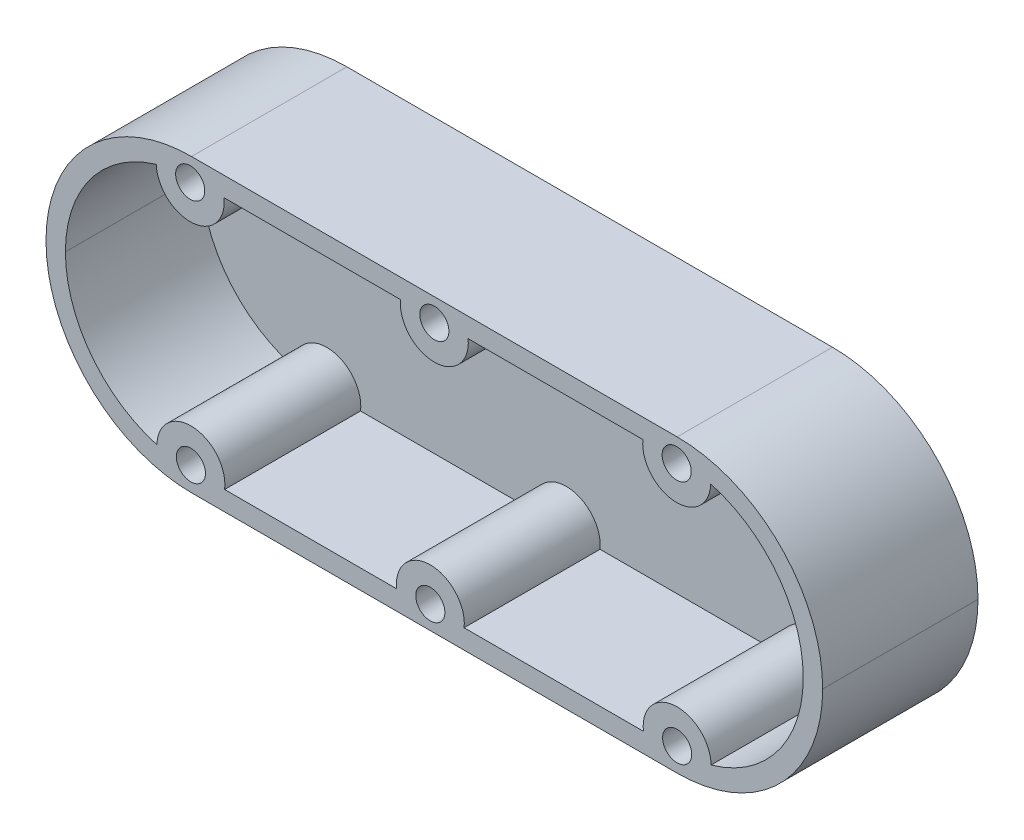
from build123d import *

# Parameters (mm, degrees)
SKETCH3_R           = 1.5
BOSS_EXTRUDE2_DEPTH = 16
SHELL4_T            = -2


with BuildPart() as part:
    # Sketch3 → Boss-Extrude2 (new body)
    with BuildSketch(Plane.XY):
        with BuildLine():
            Line((40.605667182, -0.784898421), (40.605667182, -0.764898421))
            ThreePointArc((40.605667182, -0.764898421), (36.215197832, 9.834632229), (25.615667182, 14.225101579))
            Line((25.615667182, 14.225101579), (-24.404332818, 14.225101579))
            ThreePointArc((-24.404332818, 14.225101579), (-35.003863468, 9.834632229), (-39.394332818, -0.764898421))
            Line((-39.394332818, -0.764898421), (-39.394332818, -0.784898421))
            ThreePointArc((-39.394332818, -0.784898421), (-35.003863468, -11.384429071), (-24.404332818, -15.774898421))
            Line((-24.404332818, -15.774898421), (25.615667182, -15.774898421))
            ThreePointArc((25.615667182, -15.774898421), (36.215197832, -11.384429071), (40.605667182, -0.784898421))
        make_face()
        with Locations(Location((25.569857848, 11.840225967, 0), (0, 0, 180))):
            Circle(SKETCH3_R, mode=Mode.SUBTRACT)
        with Locations(Location((25.615667182, -13.354907477, 0), (0, 0, 180))):
            Circle(SKETCH3_R, mode=Mode.SUBTRACT)
        with Locations(Location((0.19338318, -13.400716811, 0), (0, 0, 180))):
            Circle(SKETCH3_R, mode=Mode.SUBTRACT)
        with Locations(Location((0.605667182, 11.8860353, 0), (0, 0, 180))):
            Circle(SKETCH3_R, mode=Mode.SUBTRACT)
        with Locations(Location((-24.541760819, 11.840225967, 0), (0, 0, 180))):
            Circle(SKETCH3_R, mode=Mode.SUBTRACT)
        with Locations(Location((-24.468118501, -13.332659391, 0), (0, 0, 180))):
            Circle(SKETCH3_R, mode=Mode.SUBTRACT)
    extrude(amount=BOSS_EXTRUDE2_DEPTH)

    # Shell4
    shell4_openings = [part.faces().sort_by_distance(p)[0] for p in [
        (0.60782007, -0.775315064, 16),
    ]]
    offset(amount=SHELL4_T, openings=shell4_openings)


solid = part.part
